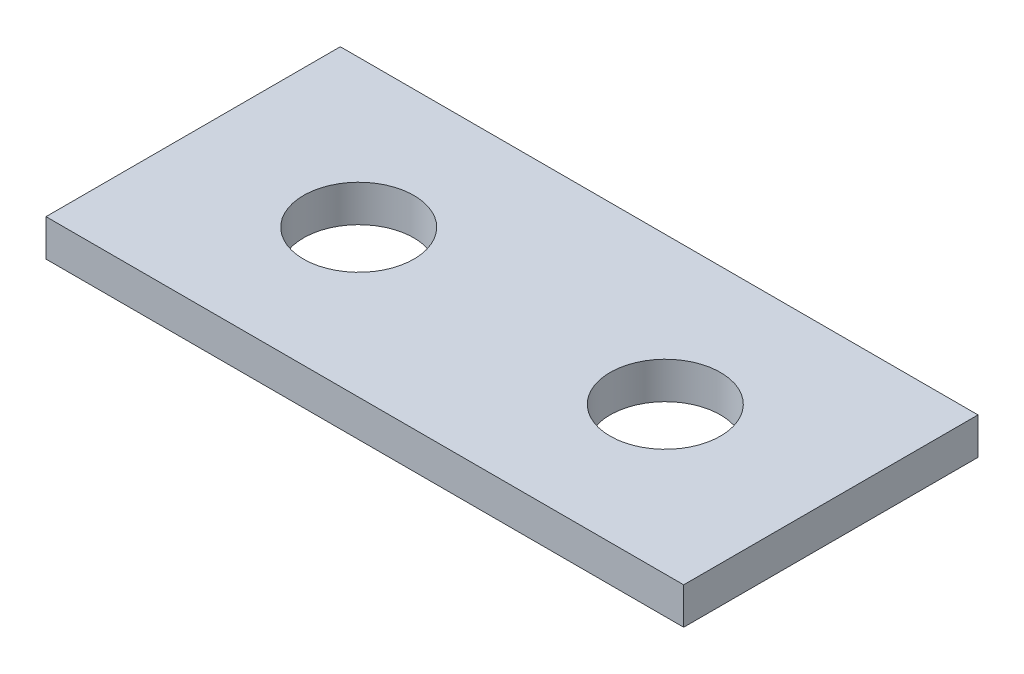
from build123d import *

# Parameters (mm, degrees)
SKETCH1_W           = 26
SKETCH1_H           = 12
BOSS_EXTRUDE1_DEPTH = 1.5
SKETCH2_R           = 2.25
CUT_EXTRUDE1_DEPTH  = 2.5


with BuildPart() as part:
    # Sketch1 → Boss-Extrude1 (new body)
    with BuildSketch(Plane(origin=(0, 0, 0), x_dir=(1, 0, 0), z_dir=(0, 1, 0))):
        Rectangle(SKETCH1_W, SKETCH1_H)
    extrude(amount=BOSS_EXTRUDE1_DEPTH)

    # Sketch2 → Cut-Extrude1 (cut, through all)
    with BuildSketch(Plane(origin=(0, 1.5, 0), x_dir=(1, 0, 0), z_dir=(0, 1, 0))):
        with Locations(Location((-6.25, 0, 0), (0, 0, 270))):  # turned: the seam where the file's is
            Circle(SKETCH2_R)
    cut_extrude1 = extrude(amount=-CUT_EXTRUDE1_DEPTH, mode=Mode.SUBTRACT)

    # Mirror1: Cut-Extrude1 across plane
    add(cut_extrude1.mirror(Plane(origin=(0, 0, 0), x_dir=(0, 0, 1), z_dir=(1, 0, 0))), mode=Mode.SUBTRACT)


solid = part.part
